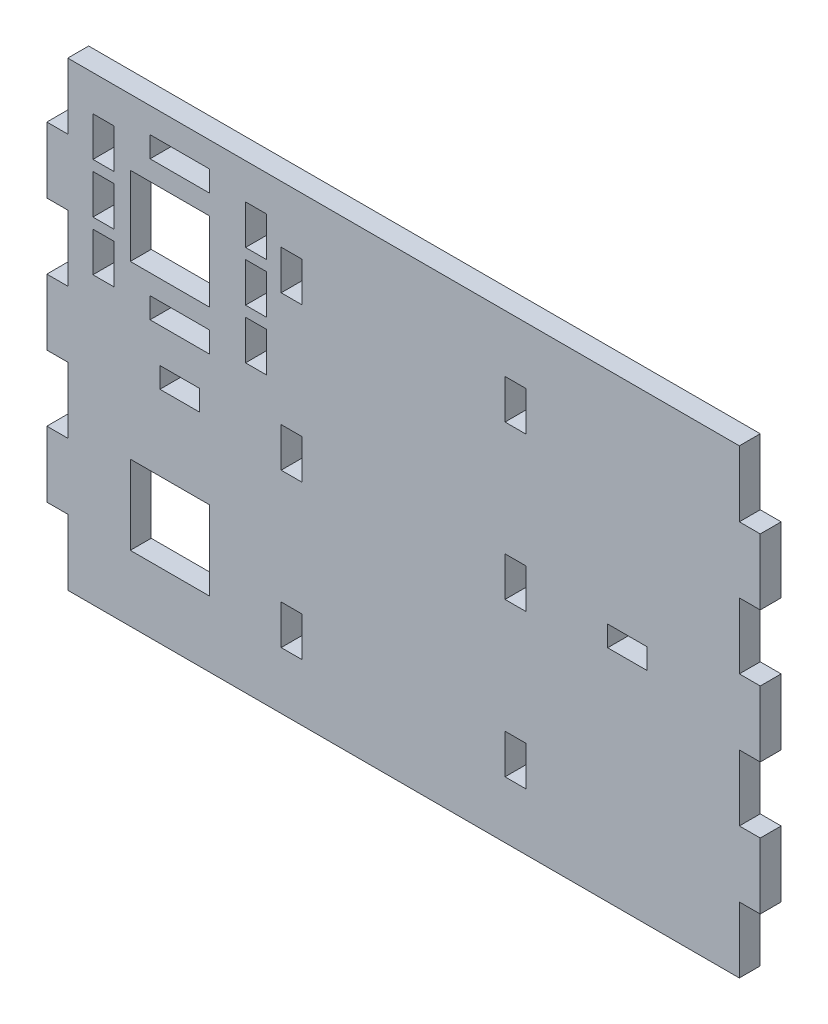
from build123d import *

# Parameters (mm, degrees)
SKETCH1_W           = 6
SKETCH1_H           = 3.125
SKETCH1_W_2         = 3.175
SKETCH1_H_2         = 6
BOSS_EXTRUDE1_DEPTH = 1.5875


with BuildPart() as part:
    # Sketch1 → Boss-Extrude1 (new body, symmetric)
    with BuildSketch(Plane.XY):
        Polygon((54.175, 0), (54.175, 5), (51, 5), (51, 15), (54.175, 15), (54.175, 25), (51, 25), (51, 35), (17, 35), (0, 35), (-17, 35), (-51, 35), (-51, 25), (-54.175, 25), (-54.175, 15), (-51, 15), (-51, 5), (-54.175, 5), (-54.175, -5), (-51, -5), (-51, -15), (-54.175, -15), (-54.175, -25), (-51, -25), (-51, -35), (0, -35), (51, -35), (51, -25), (54.175, -25), (54.175, -15), (51, -15), (51, -5), (54.175, -5), align=None)
        Polygon((-41.5, -13), (-34, -13), (-29.5, -13), (-29.5, -25), (-34, -25), (-41.5, -25), align=None, mode=Mode.SUBTRACT)
        Polygon((-18.5875, -23.333333333), (-18.5875, -20.333333333), (-15.4125, -20.333333333), (-15.4125, -26.333333333), (-18.5875, -26.333333333), align=None, mode=Mode.SUBTRACT)
        Polygon((18.5875, -20.333333333), (18.5875, -23.333333333), (18.5875, -26.333333333), (15.4125, -26.333333333), (15.4125, -20.333333333), align=None, mode=Mode.SUBTRACT)
        with Locations((-34, 0)):
            Rectangle(SKETCH1_W, SKETCH1_H, mode=Mode.SUBTRACT)
        Polygon((-38.5, 6.825), (-38.5, 10), (-34, 10), (-29.5, 10), (-29.5, 6.825), align=None, mode=Mode.SUBTRACT)
        Polygon((-47.175, 14.4125), (-45.5875, 14.4125), (-44, 14.4125), (-44, 8.4125), (-47.175, 8.4125), align=None, mode=Mode.SUBTRACT)
        with Locations((-17, 0)):
            Rectangle(SKETCH1_W_2, SKETCH1_H_2, mode=Mode.SUBTRACT)
        Polygon((-24, 14.4125), (-22.4125, 14.4125), (-20.825, 14.4125), (-20.825, 8.4125), (-24, 8.4125), align=None, mode=Mode.SUBTRACT)
        Polygon((-44, 22), (-44, 19), (-44, 16), (-45.5875, 16), (-47.175, 16), (-47.175, 22), (-45.5875, 22), align=None, mode=Mode.SUBTRACT)
        Polygon((-41.5, 25), (-34, 25), (-29.5, 25), (-29.5, 13), (-34, 13), (-41.5, 13), align=None, mode=Mode.SUBTRACT)
        Polygon((-44, 23.5875), (-45.5875, 23.5875), (-47.175, 23.5875), (-47.175, 29.5875), (-44, 29.5875), align=None, mode=Mode.SUBTRACT)
        Polygon((-38.5, 31.175), (-29.5, 31.175), (-29.5, 28), (-34, 28), (-38.5, 28), align=None, mode=Mode.SUBTRACT)
        Polygon((-20.825, 16), (-22.4125, 16), (-24, 16), (-24, 19), (-24, 22), (-22.4125, 22), (-20.825, 22), align=None, mode=Mode.SUBTRACT)
        Polygon((-18.5875, 20.333333333), (-18.5875, 23.333333333), (-18.5875, 26.333333333), (-15.4125, 26.333333333), (-15.4125, 20.333333333), align=None, mode=Mode.SUBTRACT)
        Polygon((-20.825, 23.5875), (-22.4125, 23.5875), (-24, 23.5875), (-24, 29.5875), (-20.825, 29.5875), align=None, mode=Mode.SUBTRACT)
        with Locations((17, 0)):
            Rectangle(SKETCH1_W_2, SKETCH1_H_2, mode=Mode.SUBTRACT)
        Polygon((37, 1.5625), (37, 0), (37, -1.5625), (31, -1.5625), (31, 1.5625), align=None, mode=Mode.SUBTRACT)
        Polygon((18.5875, 23.333333333), (18.5875, 20.333333333), (15.4125, 20.333333333), (15.4125, 26.333333333), (18.5875, 26.333333333), align=None, mode=Mode.SUBTRACT)
    extrude(amount=BOSS_EXTRUDE1_DEPTH, both=True)


solid = part.part
